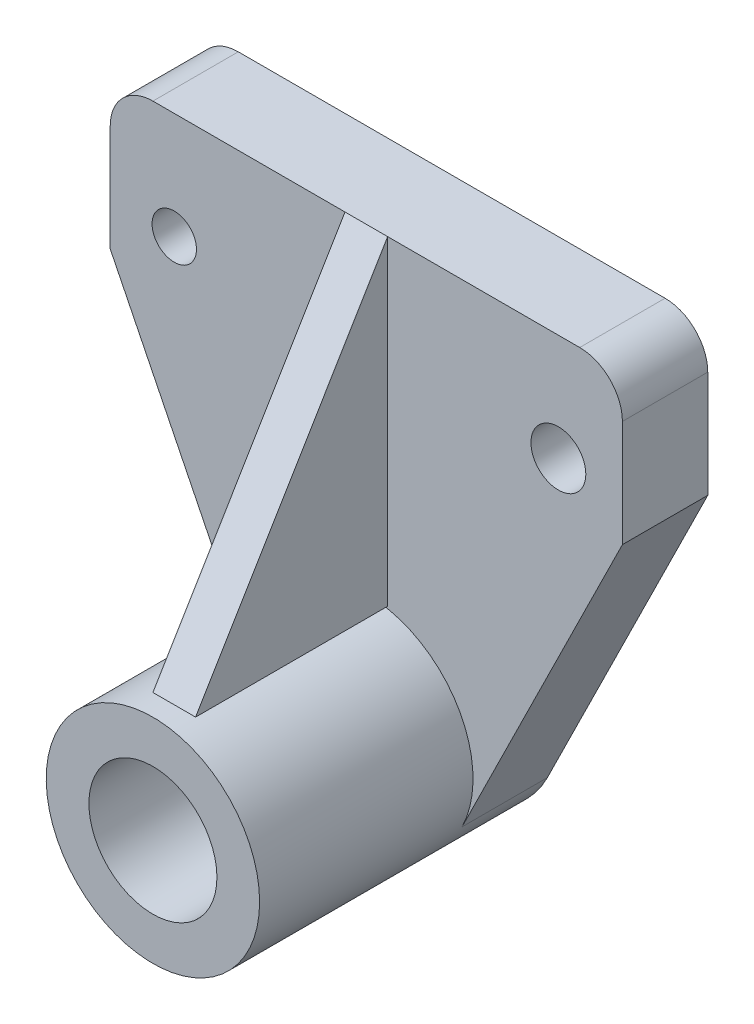
from build123d import *

# Parameters (mm, degrees)
SKETCH1_R           = 5.198777242
SKETCH1_R_2         = 6.429296023
BOSS_EXTRUDE2_DEPTH = 20
SKETCH2_R           = 25
BOSS_EXTRUDE3_DEPTH = 50
SKETCH3_R           = 15
CUT_EXTRUDE1_DEPTH  = 71
BOSS_EXTRUDE5_DEPTH = 5
FILLET1_R           = 10


with BuildPart() as part:
    # Sketch1 → Boss-Extrude2 (new body)
    with BuildSketch(Plane.XY):
        with BuildLine():
            Line((-60, 71.763138826), (60, 71.763138826))
            Line((60, 71.763138826), (60, 36.763138826))
            Line((60, 36.763138826), (22.413523621, -39.310882977))
            ThreePointArc((22.413523621, -39.310882977), (0, -53.236861174), (-22.413523621, -39.310882977))
            Line((-22.413523621, -39.310882977), (-60, 36.763138826))
            Line((-60, 36.763138826), (-60, 71.763138826))
        make_face()
        with Locations((-45, 46.763138826)):
            Circle(SKETCH1_R, mode=Mode.SUBTRACT)
        with Locations((45, 46.763138826)):
            Circle(SKETCH1_R_2, mode=Mode.SUBTRACT)
    extrude(amount=BOSS_EXTRUDE2_DEPTH)

    # Sketch2 → Boss-Extrude3 (add)
    with BuildSketch(Plane.XY.offset(20)):
        with Locations((0, -28.236861174)):
            Circle(SKETCH2_R)
    extrude(amount=BOSS_EXTRUDE3_DEPTH)

    # Sketch3 → Cut-Extrude1 (cut, through all)
    with BuildSketch(Plane.XY.offset(70)):
        with Locations((0, -28.236861174)):
            Circle(SKETCH3_R)
    extrude(amount=-CUT_EXTRUDE1_DEPTH, mode=Mode.SUBTRACT)

    # Fillet1
    fillet1_edges = [part.edges().sort_by_distance(p)[0] for p in [
        (-60, 71.763138826, 10),
        (60, 71.763138826, 10),
    ]]
    fillet(fillet1_edges, radius=FILLET1_R)


with BuildPart() as body_2:
    # Sketch4 → Boss-Extrude5 (new body, symmetric)
    with BuildSketch(Plane(origin=(0, 0, 0), x_dir=(0, 0, -1), z_dir=(1, 0, 0))):
        Polygon((-20, 71.763138826), (-20, -3.236861174), (-65, -3.236861174), align=None)
    extrude(amount=BOSS_EXTRUDE5_DEPTH, both=True)


solid = Compound([part.part, body_2.part])
